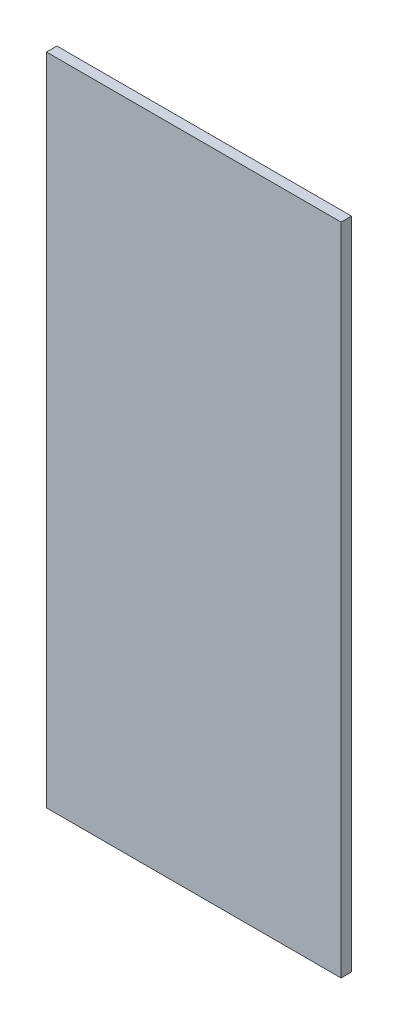
from build123d import *

# Parameters (mm, degrees)
SKETCH1_W           = 90
SKETCH1_H           = 200
BOSS_EXTRUDE2_DEPTH = 3.175


with BuildPart() as part:
    # Sketch1 → Boss-Extrude2 (new body)
    with BuildSketch(Plane.XY):
        Rectangle(SKETCH1_W, SKETCH1_H)
    extrude(amount=BOSS_EXTRUDE2_DEPTH)


solid = part.part
